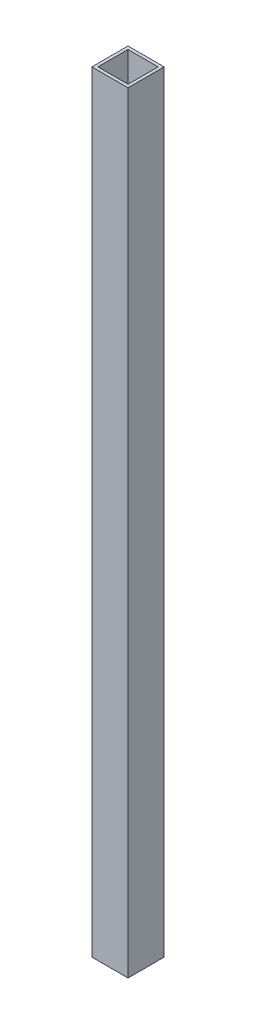
from build123d import *

# Parameters (mm, degrees)
CROQUIS2_W              = 19.05
CROQUIS2_H              = 19.05
CROQUIS2_W_2            = 15.875
CROQUIS2_H_2            = 15.875
SALIENTE_EXTRUIR1_DEPTH = 406.4


with BuildPart() as part:
    # Croquis2 → Saliente-Extruir1 (new body)
    with BuildSketch(Plane(origin=(0, 0, 0), x_dir=(1, 0, 0), z_dir=(0, 1, 0))):
        Rectangle(CROQUIS2_W, CROQUIS2_H)
        Rectangle(CROQUIS2_W_2, CROQUIS2_H_2, mode=Mode.SUBTRACT)
    extrude(amount=SALIENTE_EXTRUIR1_DEPTH)


solid = part.part
